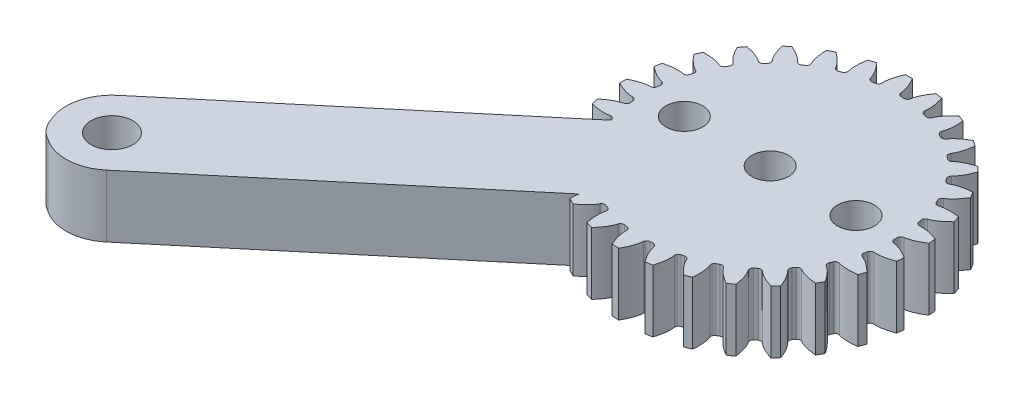
from build123d import *

# Parameters (mm, degrees)
BOSS_EXTRUDE1_DEPTH   = 5.08
CUT_EXTRUDE1_DEPTH    = 6.0800001
CUT_EXTRUDE2_DEPTH    = 6.0800001
CUT_EXTRUDE3_DEPTH    = 6.0800001
CUT_EXTRUDE4_DEPTH    = 6.0800001
CUT_EXTRUDE5_DEPTH    = 6.0800001
CUT_EXTRUDE6_DEPTH    = 6.0800001
CUT_EXTRUDE7_DEPTH    = 6.0800001
CUT_EXTRUDE8_DEPTH    = 6.0800001
CUT_EXTRUDE9_DEPTH    = 6.0800001
CUT_EXTRUDE10_DEPTH   = 6.0800001
CUT_EXTRUDE11_DEPTH   = 6.0800001
CUT_EXTRUDE12_DEPTH   = 6.0800001
CUT_EXTRUDE13_DEPTH   = 6.0800001
CUT_EXTRUDE14_DEPTH   = 6.0800001
CUT_EXTRUDE15_DEPTH   = 6.0800001
CUT_EXTRUDE16_DEPTH   = 6.0800001
CUT_EXTRUDE17_DEPTH   = 6.0800001
CUT_EXTRUDE18_DEPTH   = 6.0800001
CUT_EXTRUDE19_DEPTH   = 6.0800001
CUT_EXTRUDE20_DEPTH   = 6.0800001
CUT_EXTRUDE21_DEPTH   = 6.0800001
CUT_EXTRUDE22_DEPTH   = 6.0800001
CUT_EXTRUDE23_DEPTH   = 6.0800001
CUT_EXTRUDE24_DEPTH   = 6.0800001
CUT_EXTRUDE25_DEPTH   = 6.0800001
CUT_EXTRUDE26_DEPTH   = 6.0800001
F_3_0MM_DOWEL_HOLE1_D = 3
F_3_0MM_DOWEL_HOLE2_D = 3.4
FILLET1_R             = 0.285695909
SKETCH35_R            = 1.7
BOSS_EXTRUDE2_DEPTH   = 5.08


with BuildPart() as part:
    # Sketch1 → Boss-Extrude1 (new body)
    with BuildSketch(Plane.XZ.offset(5.08)):
        with BuildLine():
            Line((120.988344105, 8.360112759), (98.473510803, 27.252301079))
            ThreePointArc((98.473510803, 27.252301079), (94.895077389, 26.939228722), (95.208149746, 23.360795308))
            Line((95.208149746, 23.360795308), (116.748790674, 5.28605145))
            ThreePointArc((116.748790674, 5.28605145), (116.495793982, 5.294008336), (116.242709511, 5.289662267))
            ThreePointArc((116.242709511, 5.289662267), (135.702860946, -8.243787778), (121.135707512, 10.455137454))
            add(Edge.make_bspline(
                [(121.135707512, 10.455137454), (121.152351035, 9.20992249), (121.586653527, 8.700816936)],
                knots=[1.711217129, 1.711217129, 1.711217129, 2.740480077, 2.740480077, 2.740480077], degree=2, weights=[1, 0.870474175, 1]))
            ThreePointArc((121.586653527, 8.700816936), (121.364900681, 8.558866224), (121.146868004, 8.411265138))
            ThreePointArc((121.146868004, 8.411265138), (121.071416809, 8.373879223), (120.988344105, 8.360112759))
        make_face()
    extrude(amount=-BOSS_EXTRUDE1_DEPTH)

    # Sketch2 → Cut-Extrude1 (cut, through all)
    with BuildSketch(Plane(origin=(0, 0, 0), x_dir=(-1, 0, 0), z_dir=(0, 1, 0))):
        with BuildLine():
            ThreePointArc((-115.357087959, 2.85349343), (-115.640020682, 3.827622688), (-116.004297812, 4.774343824))
            add(Edge.make_bspline(
                [(-117.42496235, 3.650642325), (-116.771119594, 3.793109057), (-116.004297812, 4.774343824)],
                knots=[3.54270523, 3.54270523, 3.54270523, 4.571968178, 4.571968178, 4.571968178], degree=2, weights=[1, 0.870474175, 1]))
            ThreePointArc((-117.42496235, 3.650642325), (-117.289049937, 3.27200004), (-117.168104319, 2.888314855))
            add(Edge.make_bspline(
                [(-115.357087959, 2.85349343), (-116.561367441, 3.170586854), (-117.168104319, 2.888314855)],
                knots=[4.852809783, 4.852809783, 4.852809783, 5.882072731, 5.882072731, 5.882072731], degree=2, weights=[1, 0.870474175, 1]))
        make_face()
    extrude(amount=-CUT_EXTRUDE1_DEPTH, mode=Mode.SUBTRACT)

    # Sketch3 → Cut-Extrude2 (cut, through all)
    with BuildSketch(Plane(origin=(0, 0, 0), x_dir=(-1, 0, 0), z_dir=(0, 1, 0))):
        with BuildLine():
            ThreePointArc((-115.015876033, 0.283898413), (-115.082784951, 1.296075242), (-115.235028425, 2.298971379))
            add(Edge.make_bspline(
                [(-116.864041222, 1.506942278), (-116.194858809, 1.505521352), (-115.235028425, 2.298971379)],
                knots=[0.401112576, 0.401112576, 0.401112576, 1.430375524, 1.430375524, 1.430375524], degree=2, weights=[1, 0.870474175, 1]))
            ThreePointArc((-116.864041222, 1.506942278), (-116.812703264, 1.107935288), (-116.777066261, 0.707220716))
            add(Edge.make_bspline(
                [(-115.015876033, 0.283898413), (-116.123834418, 0.852462859), (-116.777066261, 0.707220716)],
                knots=[4.852809783, 4.852809783, 4.852809783, 5.882072731, 5.882072731, 5.882072731], degree=2, weights=[1, 0.870474175, 1]))
        make_face()
    extrude(amount=-CUT_EXTRUDE2_DEPTH, mode=Mode.SUBTRACT)

    # Sketch4 → Cut-Extrude3 (cut, through all)
    with BuildSketch(Plane(origin=(0, 0, 0), x_dir=(-1, 0, 0), z_dir=(0, 1, 0))):
        with BuildLine():
            ThreePointArc((-115.235028425, -2.298971379), (-115.082784951, -1.296075242), (-115.015876033, -0.283898413))
            add(Edge.make_bspline(
                [(-116.777066261, -0.707220716), (-116.123834418, -0.852462859), (-115.015876033, -0.283898413)],
                knots=[0.401112576, 0.401112576, 0.401112576, 1.430375524, 1.430375524, 1.430375524], degree=2, weights=[1, 0.870474175, 1]))
            ThreePointArc((-116.777066261, -0.707220716), (-116.812703264, -1.107935288), (-116.864041222, -1.506942278))
            add(Edge.make_bspline(
                [(-115.235028425, -2.298971379), (-116.194858809, -1.505521352), (-116.864041222, -1.506942278)],
                knots=[4.852809783, 4.852809783, 4.852809783, 5.882072731, 5.882072731, 5.882072731], degree=2, weights=[1, 0.870474175, 1]))
        make_face()
    extrude(amount=-CUT_EXTRUDE3_DEPTH, mode=Mode.SUBTRACT)

    # Sketch5 → Cut-Extrude4 (cut, through all)
    with BuildSketch(Plane(origin=(0, 0, 0), x_dir=(-1, 0, 0), z_dir=(0, 1, 0))):
        with BuildLine():
            ThreePointArc((-116.004297812, -4.774343824), (-115.640020682, -3.827622688), (-115.357087959, -2.85349343))
            add(Edge.make_bspline(
                [(-117.168104319, -2.888314855), (-116.561367441, -3.170586854), (-115.357087959, -2.85349343)],
                knots=[0.401112576, 0.401112576, 0.401112576, 1.430375524, 1.430375524, 1.430375524], degree=2, weights=[1, 0.870474175, 1]))
            ThreePointArc((-117.168104319, -2.888314855), (-117.289049937, -3.27200004), (-117.42496235, -3.650642325))
            add(Edge.make_bspline(
                [(-116.004297812, -4.774343824), (-116.771119594, -3.793109057), (-117.42496235, -3.650642325)],
                knots=[1.711217129, 1.711217129, 1.711217129, 2.740480077, 2.740480077, 2.740480077], degree=2, weights=[1, 0.870474175, 1]))
        make_face()
    extrude(amount=-CUT_EXTRUDE4_DEPTH, mode=Mode.SUBTRACT)

    # Sketch6 → Cut-Extrude5 (cut, through all)
    with BuildSketch(Plane(origin=(0, 0, 0), x_dir=(-1, 0, 0), z_dir=(0, 1, 0))):
        with BuildLine():
            ThreePointArc((-117.287714012, -7.026473259), (-116.728436419, -6.180194752), (-116.242709511, -5.289662267))
            add(Edge.make_bspline(
                [(-118.018870892, -4.934354601), (-117.486999322, -5.340457732), (-116.242709511, -5.289662267)],
                knots=[0.401112576, 0.401112576, 0.401112576, 1.430375524, 1.430375524, 1.430375524], degree=2, weights=[1, 0.870474175, 1]))
            ThreePointArc((-118.018870892, -4.934354601), (-118.219469842, -5.283069707), (-118.433601597, -5.623642395))
            add(Edge.make_bspline(
                [(-117.287714012, -7.026473259), (-117.825671457, -5.903335199), (-118.433601597, -5.623642395)],
                knots=[1.711217129, 1.711217129, 1.711217129, 2.740480077, 2.740480077, 2.740480077], degree=2, weights=[1, 0.870474175, 1]))
        make_face()
    extrude(amount=-CUT_EXTRUDE5_DEPTH, mode=Mode.SUBTRACT)

    # Sketch7 → Cut-Extrude6 (cut, through all)
    with BuildSketch(Plane(origin=(0, 0, 0), x_dir=(-1, 0, 0), z_dir=(0, 1, 0))):
        with BuildLine():
            ThreePointArc((-119.025265911, -8.950052613), (-118.297139054, -8.243787777), (-117.631330011, -7.478492374))
            add(Edge.make_bspline(
                [(-119.289585081, -6.74966941), (-118.857448541, -7.260614741), (-117.631330011, -7.478492374)],
                knots=[0.401112576, 0.401112576, 0.401112576, 1.430375524, 1.430375524, 1.430375524], degree=2, weights=[1, 0.870474175, 1]))
            ThreePointArc((-119.289585081, -6.74966941), (-119.560457579, -7.047108907), (-119.842796113, -7.333687197))
            add(Edge.make_bspline(
                [(-119.025265911, -8.950052613), (-119.309204727, -7.737527949), (-119.842796113, -7.333687197)],
                knots=[1.711217129, 1.711217129, 1.711217129, 2.740480077, 2.740480077, 2.740480077], degree=2, weights=[1, 0.870474175, 1]))
        make_face()
    extrude(amount=-CUT_EXTRUDE6_DEPTH, mode=Mode.SUBTRACT)

    # Sketch8 → Cut-Extrude7 (cut, through all)
    with BuildSketch(Plane(origin=(0, 0, 0), x_dir=(-1, 0, 0), z_dir=(0, 1, 0))):
        with BuildLine():
            ThreePointArc((-121.135707512, -10.455137454), (-120.272777795, -9.921910449), (-119.458019107, -9.31763649))
            add(Edge.make_bspline(
                [(-120.920829701, -8.24937718), (-120.608634416, -8.841273475), (-119.458019107, -9.31763649)],
                knots=[0.401112577, 0.401112577, 0.401112577, 1.430375524, 1.430375524, 1.430375524], degree=2, weights=[1, 0.870474175, 1]))
            ThreePointArc((-120.920829701, -8.24937718), (-121.24931005, -8.481633126), (-121.586653527, -8.700816936))
            add(Edge.make_bspline(
                [(-121.135707512, -10.455137454), (-121.152351035, -9.20992249), (-121.586653527, -8.700816936)],
                knots=[1.711217129, 1.711217129, 1.711217129, 2.740480077, 2.740480077, 2.740480077], degree=2, weights=[1, 0.870474175, 1]))
        make_face()
    extrude(amount=-CUT_EXTRUDE7_DEPTH, mode=Mode.SUBTRACT)

    # Sketch9 → Cut-Extrude8 (cut, through all)
    with BuildSketch(Plane(origin=(0, 0, 0), x_dir=(-1, 0, 0), z_dir=(0, 1, 0))):
        with BuildLine():
            ThreePointArc((-123.520356913, -11.471351688), (-122.562973968, -11.136095615), (-121.637362847, -10.72109828))
            add(Edge.make_bspline(
                [(-122.836329568, -9.363353241), (-122.658673443, -10.008524088), (-121.637362847, -10.72109828)],
                knots=[0.401112577, 0.401112577, 0.401112577, 1.430375524, 1.430375524, 1.430375524], degree=2, weights=[1, 0.870474175, 1]))
            ThreePointArc((-122.836329568, -9.363353241), (-123.207058392, -9.519565607), (-123.583633006, -9.661106145))
            add(Edge.make_bspline(
                [(-123.520356913, -11.471351688), (-123.268926911, -10.251671293), (-123.583633006, -9.661106145)],
                knots=[1.711217129, 1.711217129, 1.711217129, 2.740480077, 2.740480077, 2.740480077], degree=2, weights=[1, 0.870474175, 1]))
        make_face()
    extrude(amount=-CUT_EXTRUDE8_DEPTH, mode=Mode.SUBTRACT)

    # Sketch10 → Cut-Extrude9 (cut, through all)
    with BuildSketch(Plane(origin=(0, 0, 0), x_dir=(-1, 0, 0), z_dir=(0, 1, 0))):
        with BuildLine():
            ThreePointArc((-126.067710557, -11.951178266), (-125.060640548, -11.829569328), (-124.06745754, -11.623253429))
            add(Edge.make_bspline(
                [(-124.946518037, -10.039509311), (-124.911708074, -10.707787237), (-124.06745754, -11.623253429)],
                knots=[0.401112576, 0.401112576, 0.401112576, 1.430375524, 1.430375524, 1.430375524], degree=2, weights=[1, 0.870474175, 1]))
            ThreePointArc((-124.946518037, -10.039509311), (-125.342160468, -10.11237378), (-125.740358009, -10.169652769))
            add(Edge.make_bspline(
                [(-126.067710557, -11.951178266), (-125.559963617, -10.814063339), (-125.740358009, -10.169652769)],
                knots=[1.711217129, 1.711217129, 1.711217129, 2.740480077, 2.740480077, 2.740480077], degree=2, weights=[1, 0.870474175, 1]))
        make_face()
    extrude(amount=-CUT_EXTRUDE9_DEPTH, mode=Mode.SUBTRACT)

    # Sketch11 → Cut-Extrude10 (cut, through all)
    with BuildSketch(Plane(origin=(0, 0, 0), x_dir=(-1, 0, 0), z_dir=(0, 1, 0))):
        with BuildLine():
            ThreePointArc((-128.658657019, -11.872181032), (-127.64898942, -11.969905526), (-126.634674659, -11.981918167))
            add(Edge.make_bspline(
                [(-127.15272504, -10.246229084), (-127.262388915, -10.906366157), (-126.634674659, -11.981918167)],
                knots=[0.401112576, 0.401112576, 0.401112576, 1.430375524, 1.430375524, 1.430375524], degree=2, weights=[1, 0.870474175, 1]))
            ThreePointArc((-127.15272504, -10.246229084), (-127.554781278, -10.232338595), (-127.955982471, -10.202677732))
            add(Edge.make_bspline(
                [(-128.658657019, -11.872181032), (-127.918334824, -10.870801803), (-127.955982471, -10.202677732)],
                knots=[1.711217129, 1.711217129, 1.711217129, 2.740480077, 2.740480077, 2.740480077], degree=2, weights=[1, 0.870474175, 1]))
        make_face()
    extrude(amount=-CUT_EXTRUDE10_DEPTH, mode=Mode.SUBTRACT)

    # Sketch12 → Cut-Extrude11 (cut, through all)
    with BuildSketch(Plane(origin=(0, 0, 0), x_dir=(-1, 0, 0), z_dir=(0, 1, 0))):
        with BuildLine():
            ThreePointArc((-131.172046522, -11.238053807), (-130.206992268, -11.550542245), (-129.218973986, -11.780321728))
            add(Edge.make_bspline(
                [(-129.351790791, -9.973846573), (-129.600800742, -10.594975516), (-129.218973986, -11.780321728)],
                knots=[0.401112576, 0.401112576, 0.401112576, 1.430375524, 1.430375524, 1.430375524], degree=2, weights=[1, 0.870474175, 1]))
            ThreePointArc((-129.351790791, -9.973846573), (-129.741461132, -9.873850629), (-130.126906256, -9.758636823))
            add(Edge.make_bspline(
                [(-131.172046522, -11.238053807), (-130.233765715, -10.419233657), (-130.126906256, -9.758636823)],
                knots=[1.711217129, 1.711217129, 1.711217129, 2.740480077, 2.740480077, 2.740480077], degree=2, weights=[1, 0.870474175, 1]))
        make_face()
    extrude(amount=-CUT_EXTRUDE11_DEPTH, mode=Mode.SUBTRACT)

    # Sketch13 → Cut-Extrude12 (cut, through all)
    with BuildSketch(Plane(origin=(0, 0, 0), x_dir=(-1, 0, 0), z_dir=(0, 1, 0))):
        with BuildLine():
            ThreePointArc((-133.490355767, -10.078447677), (-132.615039722, -10.591088446), (-131.699516555, -11.027890538))
            add(Edge.make_bspline(
                [(-131.440889417, -9.235098081), (-131.817602016, -9.788175596), (-131.699516555, -11.027890538)],
                knots=[0.401112576, 0.401112576, 0.401112576, 1.430375524, 1.430375524, 1.430375524], degree=2, weights=[1, 0.870474175, 1]))
            ThreePointArc((-131.440889417, -9.235098081), (-131.799953311, -9.053672382), (-132.151619379, -8.858292903))
            add(Edge.make_bspline(
                [(-133.490355767, -10.078447677), (-132.397989315, -9.480473725), (-132.151619379, -8.858292903)],
                knots=[1.711217129, 1.711217129, 1.711217129, 2.740480077, 2.740480077, 2.740480077], degree=2, weights=[1, 0.870474175, 1]))
        make_face()
    extrude(amount=-CUT_EXTRUDE12_DEPTH, mode=Mode.SUBTRACT)

    # Sketch14 → Cut-Extrude13 (cut, through all)
    with BuildSketch(Plane(origin=(0, 0, 0), x_dir=(-1, 0, 0), z_dir=(0, 1, 0))):
        with BuildLine():
            ThreePointArc((-135.50518319, -8.447584535), (-134.760534159, -9.136407123), (-133.960314953, -9.759807443))
            add(Edge.make_bspline(
                [(-133.32233699, -8.064526667), (-133.809137575, -8.523691464), (-133.960314953, -9.759807443)],
                knots=[0.401112576, 0.401112576, 0.401112576, 1.430375524, 1.430375524, 1.430375524], degree=2, weights=[1, 0.870474175, 1]))
            ThreePointArc((-133.32233699, -8.064526667), (-133.634005007, -7.810154476), (-133.935448505, -7.543745052))
            add(Edge.make_bspline(
                [(-135.50518319, -8.447584535), (-134.309808935, -8.098417378), (-133.935448505, -7.543745052)],
                knots=[1.711217129, 1.711217129, 1.711217129, 2.740480077, 2.740480077, 2.740480077], degree=2, weights=[1, 0.870474175, 1]))
        make_face()
    extrude(amount=-CUT_EXTRUDE13_DEPTH, mode=Mode.SUBTRACT)

    # Sketch15 → Cut-Extrude14 (cut, through all)
    with BuildSketch(Plane(origin=(0, 0, 0), x_dir=(-1, 0, 0), z_dir=(0, 1, 0))):
        with BuildLine():
            ThreePointArc((-137.122317699, -6.421721728), (-136.543154645, -7.254517557), (-135.895656759, -8.035366599))
            add(Edge.make_bspline(
                [(-134.908159112, -6.516866949), (-135.482285429, -6.860648992), (-135.895656759, -8.035366599)],
                knots=[0.401112576, 0.401112576, 0.401112576, 1.430375524, 1.430375524, 1.430375524], degree=2, weights=[1, 0.870474175, 1]))
            ThreePointArc((-134.908159112, -6.516866949), (-135.157858003, -6.201442428), (-135.394983768, -5.876460066))
            add(Edge.make_bspline(
                [(-137.122317699, -6.421721728), (-135.879830013, -6.337688035), (-135.394983768, -5.876460066)],
                knots=[1.711217129, 1.711217129, 1.711217129, 2.740480077, 2.740480077, 2.740480077], degree=2, weights=[1, 0.870474175, 1]))
        make_face()
    extrude(amount=-CUT_EXTRUDE14_DEPTH, mode=Mode.SUBTRACT)

    # Sketch16 → Cut-Extrude15 (cut, through all)
    with BuildSketch(Plane(origin=(0, 0, 0), x_dir=(-1, 0, 0), z_dir=(0, 1, 0))):
        with BuildLine():
            ThreePointArc((-138.266143883, -4.095586351), (-137.879547825, -5.033414813), (-137.415047543, -5.935200944))
            add(Edge.make_bspline(
                [(-136.124204504, -4.664485776), (-136.758811043, -4.876810199), (-137.415047543, -5.935200944)],
                knots=[0.401112576, 0.401112576, 0.401112576, 1.430375524, 1.430375524, 1.430375524], degree=2, weights=[1, 0.870474175, 1]))
            ThreePointArc((-136.124204504, -4.664485776), (-136.300258625, -4.302757824), (-136.46197892, -3.934398339))
            add(Edge.make_bspline(
                [(-138.266143883, -4.095586351), (-137.034640109, -4.280615444), (-136.46197892, -3.934398339)],
                knots=[1.711217129, 1.711217129, 1.711217129, 2.740480077, 2.740480077, 2.740480077], degree=2, weights=[1, 0.870474175, 1]))
        make_face()
    extrude(amount=-CUT_EXTRUDE15_DEPTH, mode=Mode.SUBTRACT)

    # Sketch17 → Cut-Extrude16 (cut, through all)
    with BuildSketch(Plane(origin=(0, 0, 0), x_dir=(-1, 0, 0), z_dir=(0, 1, 0))):
        with BuildLine():
            ThreePointArc((-138.883177701, -1.577945908), (-138.707225441, -2.576955187), (-138.447442279, -3.557511889))
            add(Edge.make_bspline(
                [(-136.913612234, -2.593998431), (-137.579025499, -2.664937181), (-138.447442279, -3.557511889)],
                knots=[0.401112576, 0.401112576, 0.401112576, 1.430375524, 1.430375524, 1.430375524], degree=2, weights=[1, 0.870474175, 1]))
            ThreePointArc((-136.913612234, -2.593998431), (-137.00778949, -2.202881047), (-137.086542454, -1.808368519))
            add(Edge.make_bspline(
                [(-138.883177701, -1.577945908), (-137.720241586, -2.023386032), (-137.086542454, -1.808368519)],
                knots=[1.711217129, 1.711217129, 1.711217129, 2.740480077, 2.740480077, 2.740480077], degree=2, weights=[1, 0.870474175, 1]))
        make_face()
    extrude(amount=-CUT_EXTRUDE16_DEPTH, mode=Mode.SUBTRACT)

    # Sketch18 → Cut-Extrude17 (cut, through all)
    with BuildSketch(Plane(origin=(0, 0, 0), x_dir=(-1, 0, 0), z_dir=(0, 1, 0))):
        with BuildLine():
            ThreePointArc((-138.944567336, 1.013477532), (-138.987486207, 0), (-138.944567336, -1.013477532))
            add(Edge.make_bspline(
                [(-137.239470473, -0.402218604), (-137.904576481, -0.328454662), (-138.944567336, -1.013477532)],
                knots=[3.54270523, 3.54270523, 3.54270523, 4.571968178, 4.571968178, 4.571968178], degree=2, weights=[1, 0.870474175, 1]))
            ThreePointArc((-137.239470473, -0.402218604), (-137.247367241, 0), (-137.239470473, 0.402218604))
            add(Edge.make_bspline(
                [(-138.944567336, 1.013477532), (-137.904576481, 0.328454662), (-137.239470473, 0.402218604)],
                knots=[1.711217129, 1.711217129, 1.711217129, 2.740480077, 2.740480077, 2.740480077], degree=2, weights=[1, 0.870474175, 1]))
        make_face()
    extrude(amount=-CUT_EXTRUDE17_DEPTH, mode=Mode.SUBTRACT)

    # Sketch19 → Cut-Extrude18 (cut, through all)
    with BuildSketch(Plane(origin=(0, 0, 0), x_dir=(-1, 0, 0), z_dir=(0, 1, 0))):
        with BuildLine():
            ThreePointArc((-138.447442279, 3.557511889), (-138.707225441, 2.576955187), (-138.883177701, 1.577945908))
            add(Edge.make_bspline(
                [(-137.086542454, 1.808368519), (-137.720241586, 2.023386032), (-138.883177701, 1.577945908)],
                knots=[3.54270523, 3.54270523, 3.54270523, 4.571968178, 4.571968178, 4.571968178], degree=2, weights=[1, 0.870474175, 1]))
            ThreePointArc((-137.086542454, 1.808368519), (-137.00778949, 2.202881047), (-136.913612234, 2.593998431))
            add(Edge.make_bspline(
                [(-138.447442279, 3.557511889), (-137.579025499, 2.664937181), (-136.913612234, 2.593998431)],
                knots=[4.852809783, 4.852809783, 4.852809783, 5.882072731, 5.882072731, 5.882072731], degree=2, weights=[1, 0.870474175, 1]))
        make_face()
    extrude(amount=-CUT_EXTRUDE18_DEPTH, mode=Mode.SUBTRACT)

    # Sketch20 → Cut-Extrude19 (cut, through all)
    with BuildSketch(Plane(origin=(0, 0, 0), x_dir=(-1, 0, 0), z_dir=(0, 1, 0))):
        with BuildLine():
            ThreePointArc((-137.415047543, 5.935200944), (-137.879547825, 5.033414813), (-138.266143883, 4.095586351))
            add(Edge.make_bspline(
                [(-136.46197892, 3.934398339), (-137.034640109, 4.280615444), (-138.266143883, 4.095586351)],
                knots=[3.54270523, 3.54270523, 3.54270523, 4.571968178, 4.571968178, 4.571968178], degree=2, weights=[1, 0.870474175, 1]))
            ThreePointArc((-136.46197892, 3.934398339), (-136.300258625, 4.302757824), (-136.124204504, 4.664485776))
            add(Edge.make_bspline(
                [(-137.415047543, 5.935200944), (-136.758811043, 4.876810199), (-136.124204504, 4.664485776)],
                knots=[4.852809783, 4.852809783, 4.852809783, 5.882072731, 5.882072731, 5.882072731], degree=2, weights=[1, 0.870474175, 1]))
        make_face()
    extrude(amount=-CUT_EXTRUDE19_DEPTH, mode=Mode.SUBTRACT)

    # Sketch21 → Cut-Extrude20 (cut, through all)
    with BuildSketch(Plane(origin=(0, 0, 0), x_dir=(-1, 0, 0), z_dir=(0, 1, 0))):
        with BuildLine():
            ThreePointArc((-135.895656759, 8.035366599), (-136.543154645, 7.254517557), (-137.122317699, 6.421721728))
            add(Edge.make_bspline(
                [(-135.394983768, 5.876460066), (-135.879830013, 6.337688035), (-137.122317699, 6.421721728)],
                knots=[3.54270523, 3.54270523, 3.54270523, 4.571968178, 4.571968178, 4.571968178], degree=2, weights=[1, 0.870474175, 1]))
            ThreePointArc((-135.394983768, 5.876460066), (-135.157858003, 6.201442428), (-134.908159112, 6.516866949))
            add(Edge.make_bspline(
                [(-135.895656759, 8.035366599), (-135.482285429, 6.860648992), (-134.908159112, 6.516866949)],
                knots=[4.852809783, 4.852809783, 4.852809783, 5.882072731, 5.882072731, 5.882072731], degree=2, weights=[1, 0.870474175, 1]))
        make_face()
    extrude(amount=-CUT_EXTRUDE20_DEPTH, mode=Mode.SUBTRACT)

    # Sketch22 → Cut-Extrude21 (cut, through all)
    with BuildSketch(Plane(origin=(0, 0, 0), x_dir=(-1, 0, 0), z_dir=(0, 1, 0))):
        with BuildLine():
            ThreePointArc((-133.960314953, 9.759807443), (-134.760534159, 9.136407123), (-135.50518319, 8.447584535))
            add(Edge.make_bspline(
                [(-133.935448505, 7.543745052), (-134.309808935, 8.098417378), (-135.50518319, 8.447584535)],
                knots=[3.54270523, 3.54270523, 3.54270523, 4.571968178, 4.571968178, 4.571968178], degree=2, weights=[1, 0.870474175, 1]))
            ThreePointArc((-133.935448505, 7.543745052), (-133.634005007, 7.810154476), (-133.32233699, 8.064526667))
            add(Edge.make_bspline(
                [(-133.960314953, 9.759807443), (-133.809137575, 8.523691464), (-133.32233699, 8.064526667)],
                knots=[4.852809783, 4.852809783, 4.852809783, 5.882072731, 5.882072731, 5.882072731], degree=2, weights=[1, 0.870474175, 1]))
        make_face()
    extrude(amount=-CUT_EXTRUDE21_DEPTH, mode=Mode.SUBTRACT)

    # Sketch23 → Cut-Extrude22 (cut, through all)
    with BuildSketch(Plane(origin=(0, 0, 0), x_dir=(-1, 0, 0), z_dir=(0, 1, 0))):
        with BuildLine():
            ThreePointArc((-131.699516555, 11.027890538), (-132.615039722, 10.591088446), (-133.490355767, 10.078447677))
            add(Edge.make_bspline(
                [(-132.151619379, 8.858292903), (-132.397989315, 9.480473725), (-133.490355767, 10.078447677)],
                knots=[3.54270523, 3.54270523, 3.54270523, 4.571968178, 4.571968178, 4.571968178], degree=2, weights=[1, 0.870474175, 1]))
            ThreePointArc((-132.151619379, 8.858292903), (-131.799953311, 9.053672382), (-131.440889417, 9.235098081))
            add(Edge.make_bspline(
                [(-131.699516555, 11.027890538), (-131.817602016, 9.788175596), (-131.440889417, 9.235098081)],
                knots=[4.852809783, 4.852809783, 4.852809783, 5.882072731, 5.882072731, 5.882072731], degree=2, weights=[1, 0.870474175, 1]))
        make_face()
    extrude(amount=-CUT_EXTRUDE22_DEPTH, mode=Mode.SUBTRACT)

    # Sketch24 → Cut-Extrude23 (cut, through all)
    with BuildSketch(Plane(origin=(0, 0, 0), x_dir=(-1, 0, 0), z_dir=(0, 1, 0))):
        with BuildLine():
            ThreePointArc((-129.218973986, 11.780321728), (-130.206992268, 11.550542245), (-131.172046522, 11.238053807))
            add(Edge.make_bspline(
                [(-130.126906256, 9.758636823), (-130.233765715, 10.419233657), (-131.172046522, 11.238053807)],
                knots=[3.54270523, 3.54270523, 3.54270523, 4.571968178, 4.571968178, 4.571968178], degree=2, weights=[1, 0.870474175, 1]))
            ThreePointArc((-130.126906256, 9.758636823), (-129.741461132, 9.873850629), (-129.351790791, 9.973846573))
            add(Edge.make_bspline(
                [(-129.218973986, 11.780321728), (-129.600800742, 10.594975516), (-129.351790791, 9.973846573)],
                knots=[4.852809783, 4.852809783, 4.852809783, 5.882072731, 5.882072731, 5.882072731], degree=2, weights=[1, 0.870474175, 1]))
        make_face()
    extrude(amount=-CUT_EXTRUDE23_DEPTH, mode=Mode.SUBTRACT)

    # Sketch25 → Cut-Extrude24 (cut, through all)
    with BuildSketch(Plane(origin=(0, 0, 0), x_dir=(-1, 0, 0), z_dir=(0, 1, 0))):
        with BuildLine():
            ThreePointArc((-126.634674659, 11.981918167), (-127.64898942, 11.969905526), (-128.658657019, 11.872181032))
            add(Edge.make_bspline(
                [(-127.955982471, 10.202677732), (-127.918334824, 10.870801803), (-128.658657019, 11.872181032)],
                knots=[3.54270523, 3.54270523, 3.54270523, 4.571968178, 4.571968178, 4.571968178], degree=2, weights=[1, 0.870474175, 1]))
            ThreePointArc((-127.955982471, 10.202677732), (-127.554781278, 10.232338595), (-127.15272504, 10.246229084))
            add(Edge.make_bspline(
                [(-126.634674659, 11.981918167), (-127.262388915, 10.906366157), (-127.15272504, 10.246229084)],
                knots=[4.852809783, 4.852809783, 4.852809783, 5.882072731, 5.882072731, 5.882072731], degree=2, weights=[1, 0.870474175, 1]))
        make_face()
    extrude(amount=-CUT_EXTRUDE24_DEPTH, mode=Mode.SUBTRACT)

    # Sketch26 → Cut-Extrude25 (cut, through all)
    with BuildSketch(Plane(origin=(0, 0, 0), x_dir=(-1, 0, 0), z_dir=(0, 1, 0))):
        with BuildLine():
            ThreePointArc((-124.06745754, 11.623253429), (-125.060640548, 11.829569328), (-126.067710557, 11.951178266))
            add(Edge.make_bspline(
                [(-125.740358009, 10.169652769), (-125.559963617, 10.814063339), (-126.067710557, 11.951178266)],
                knots=[3.54270523, 3.54270523, 3.54270523, 4.571968178, 4.571968178, 4.571968178], degree=2, weights=[1, 0.870474175, 1]))
            ThreePointArc((-125.740358009, 10.169652769), (-125.342160468, 10.11237378), (-124.946518037, 10.039509311))
            add(Edge.make_bspline(
                [(-124.06745754, 11.623253429), (-124.911708074, 10.707787237), (-124.946518037, 10.039509311)],
                knots=[4.852809783, 4.852809783, 4.852809783, 5.882072731, 5.882072731, 5.882072731], degree=2, weights=[1, 0.870474175, 1]))
        make_face()
    extrude(amount=-CUT_EXTRUDE25_DEPTH, mode=Mode.SUBTRACT)

    # Sketch27 → Cut-Extrude26 (cut, through all)
    with BuildSketch(Plane(origin=(0, 0, 0), x_dir=(-1, 0, 0), z_dir=(0, 1, 0))):
        with BuildLine():
            ThreePointArc((-121.637362847, 10.72109828), (-122.562973968, 11.136095615), (-123.520356913, 11.471351688))
            add(Edge.make_bspline(
                [(-123.583633006, 9.661106145), (-123.268926911, 10.251671293), (-123.520356913, 11.471351688)],
                knots=[3.54270523, 3.54270523, 3.54270523, 4.571968178, 4.571968178, 4.571968178], degree=2, weights=[1, 0.870474175, 1]))
            ThreePointArc((-123.583633006, 9.661106145), (-123.207058392, 9.519565607), (-122.836329568, 9.363353241))
            add(Edge.make_bspline(
                [(-121.637362847, 10.72109828), (-122.658673442, 10.008524088), (-122.836329568, 9.363353241)],
                knots=[4.852809783, 4.852809783, 4.852809783, 5.882072731, 5.882072731, 5.882072731], degree=2, weights=[1, 0.870474175, 1]))
        make_face()
    extrude(amount=-CUT_EXTRUDE26_DEPTH, mode=Mode.SUBTRACT)

    # Ø3.0mm Dowel Hole1 (through all)
    with Locations(Plane(origin=(0, 0, 0), x_dir=(1, 0, 0), z_dir=(0, 1, 0))):
        with Locations((127, 0), (120, 0), (134, 0)):
            Hole(F_3_0MM_DOWEL_HOLE1_D / 2)

    # Ø3.0mm Dowel Hole2 (through all)
    with Locations(Plane(origin=(0, -5.08, 0), x_dir=(-1, 0, 0), z_dir=(0, -1, 0))):
        with Locations((-97.813706717, -24.490207929)):
            Hole(F_3_0MM_DOWEL_HOLE2_D / 2)

    # Fillet1
    fillet1_edges = [part.edges().sort_by_distance(p)[0] for p in [
        (116.777066261, -2.54, 0.707220716),
        (131.440889417, -2.54, 9.235098081),
        (136.913612234, -2.54, 2.593998431),
        (137.239470473, -2.54, 0.402218604),
        (117.42496235, -2.54, -3.650642325),
        (122.836329568, -2.54, -9.363353241),
        (122.836329568, -2.54, 9.363353241),
        (123.583633006, -2.54, -9.661106145),
        (133.32233699, -2.54, 8.064526667),
        (120.920829701, -2.54, -8.24937718),
        (127.15272504, -2.54, 10.246229084),
        (121.586653527, -2.54, -8.700816936),
        (116.864041222, -2.54, -1.506942278),
        (118.018870892, -2.54, -4.934354601),
        (117.168104319, -2.54, 2.888314855),
        (118.433601597, -2.54, -5.623642395),
        (119.289585081, -2.54, -6.74966941),
        (136.124204504, -2.54, 4.664485776),
        (119.842796113, -2.54, -7.333687197),
        (134.908159112, -2.54, 6.516866949),
        (124.946518037, -2.54, -10.039509311),
        (129.351790791, -2.54, 9.973846573),
        (125.740358009, -2.54, -10.169652769),
        (124.946518037, -2.54, 10.039509311),
        (127.15272504, -2.54, -10.246229084),
        (116.777066261, -2.54, -0.707220716),
        (127.955982471, -2.54, -10.202677732),
        (116.864041222, -2.54, 1.506942278),
        (129.351790791, -2.54, -9.973846573),
        (117.42496235, -2.54, 3.650642325),
        (130.126906256, -2.54, -9.758636823),
        (123.583633006, -2.54, 9.661106145),
        (131.440889417, -2.54, -9.235098081),
        (121.586653527, -2.54, 8.700816936),
        (132.151619379, -2.54, -8.858292903),
        (137.086542454, -2.54, 1.808368519),
        (134.908159112, -2.54, -6.516866949),
        (136.46197892, -2.54, 3.934398339),
        (135.394983768, -2.54, -5.876460066),
        (133.935448505, -2.54, 7.543745052),
        (133.32233699, -2.54, -8.064526667),
        (135.394983768, -2.54, 5.876460066),
        (133.935448505, -2.54, -7.543745052),
        (132.151619379, -2.54, 8.858292903),
        (136.124204504, -2.54, -4.664485776),
        (130.126906256, -2.54, 9.758636823),
        (136.46197892, -2.54, -3.934398339),
        (127.955982471, -2.54, 10.202677732),
        (136.913612234, -2.54, -2.593998431),
        (125.740358009, -2.54, 10.169652769),
        (137.086542454, -2.54, -1.808368519),
        (137.239470473, -2.54, -0.402218604),
        (117.168104319, -2.54, -2.888314855),
    ]]
    fillet(fillet1_edges, radius=FILLET1_R)

    # Sketch35 → Boss-Extrude2 (add)
    with BuildSketch(Plane(origin=(0, 0, 0), x_dir=(1, 0, 0), z_dir=(0, 1, 0))):
        with BuildLine():
            Line((117.28411531, -3.257317926), (95.403253181, -21.617541267))
            ThreePointArc((95.403253181, -21.617541267), (94.941040055, -26.900661465), (100.224160253, -27.362874591))
            Line((100.224160253, -27.362874591), (121.190533062, -9.769998901))
            Line((121.190533062, -9.769998901), (122.105022382, -9.002651249))
            Line((122.105022382, -9.002651249), (117.28411531, -3.257317926))
        make_face()
        with Locations((97.813706717, -24.490207929)):
            Circle(SKETCH35_R, mode=Mode.SUBTRACT)
    extrude(amount=-BOSS_EXTRUDE2_DEPTH)


solid = part.part
